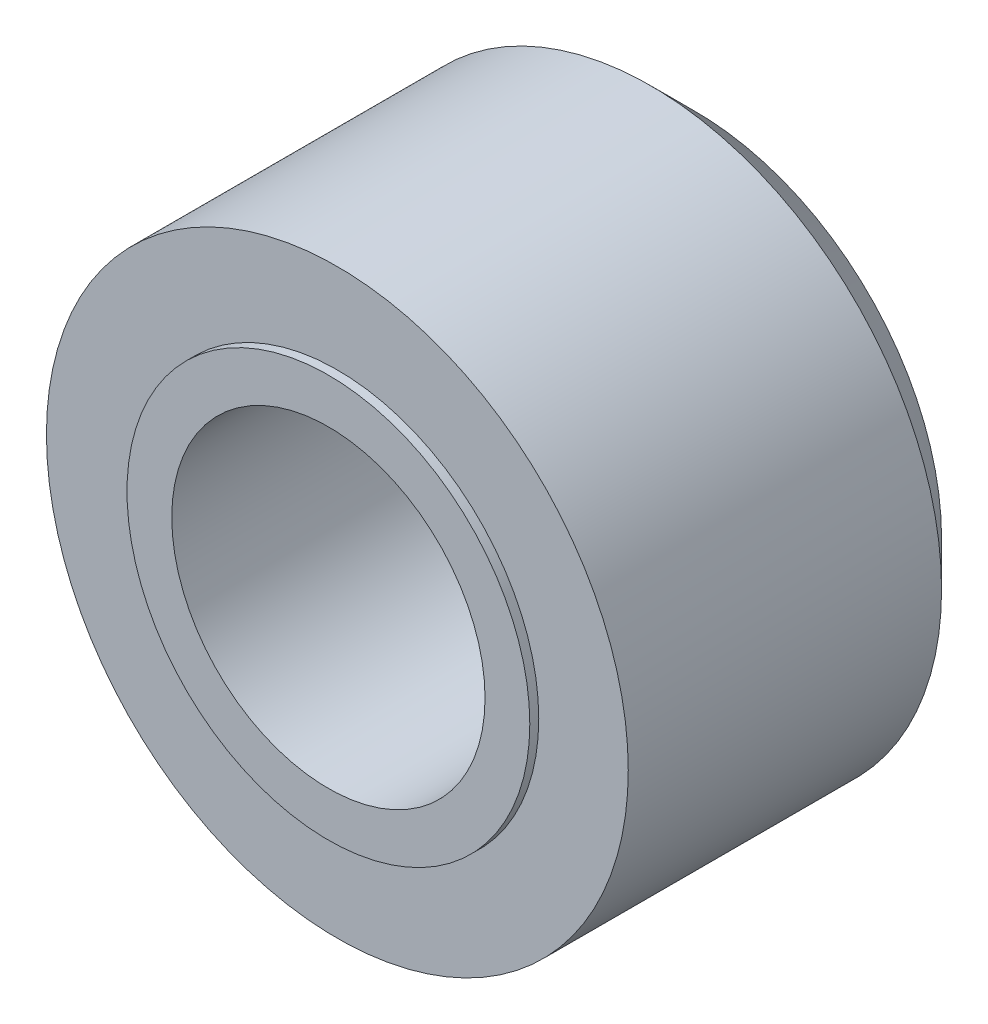
from build123d import *

# Parameters (mm, degrees)
SKETCH1_R           = 3.25
SKETCH1_R_2         = 1.75
BOSS_EXTRUDE1_DEPTH = 4
SKETCH2_R           = 2.25
SKETCH2_R_2         = 1.75
BOSS_EXTRUDE2_DEPTH = 0.1
CHAMFER1_SIZE       = 0.5


with BuildPart() as part:
    # Sketch1 → Boss-Extrude1 (new body)
    with BuildSketch(Plane.XY):
        Circle(SKETCH1_R)
        Circle(SKETCH1_R_2, mode=Mode.SUBTRACT)
    extrude(amount=BOSS_EXTRUDE1_DEPTH)

    # Sketch2 → Boss-Extrude2 (add)
    with BuildSketch(Plane.XY.offset(4)):
        Circle(SKETCH2_R)
        Circle(SKETCH2_R_2, mode=Mode.SUBTRACT)
    extrude(amount=BOSS_EXTRUDE2_DEPTH)

    # Chamfer1
    chamfer1_edges = [part.edges().sort_by_distance(p)[0] for p in [
        (-3.25, 0, 0),
    ]]
    chamfer(chamfer1_edges, length=CHAMFER1_SIZE)


solid = part.part
